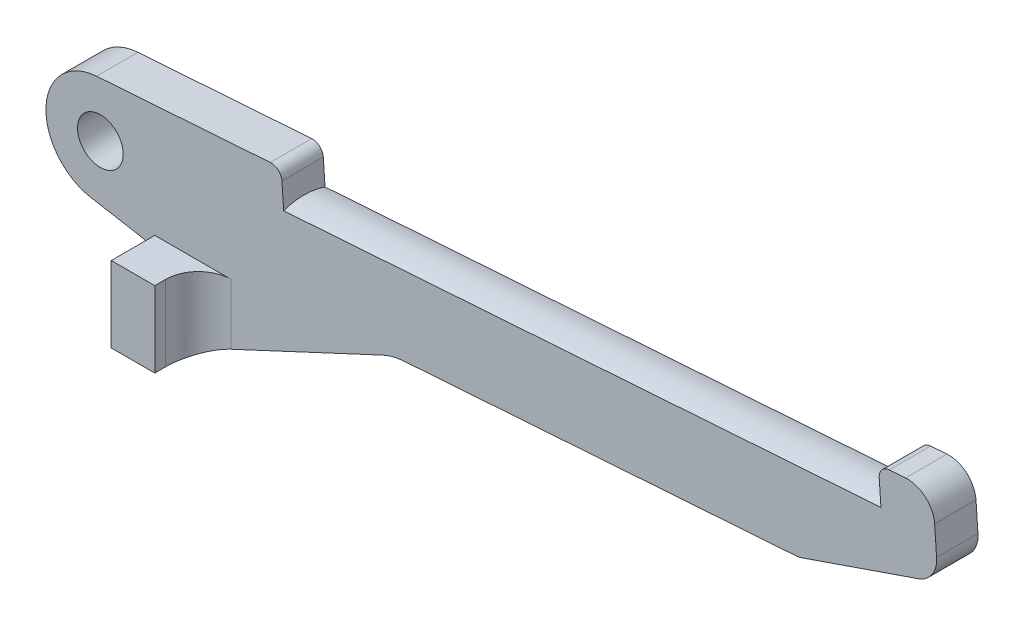
from build123d import *

# Parameters (mm, degrees)
SKETCH1_R           = 4.2
BOSS_EXTRUDE1_DEPTH = 7.6
SKETCH2_W           = 8
SKETCH2_H           = 13.917535926
BOSS_EXTRUDE2_DEPTH = 8
FILLET1_R           = 6
CUT_EXTRUDE2_DEPTH  = 110
FILLET2_R           = 2


with BuildPart() as part:
    # Sketch1 → Boss-Extrude1 (new body)
    with BuildSketch(Plane.XY):
        with BuildLine():
            Line((-1.736481777, -9.84807753), (7.520944533, -11.48041156))
            ThreePointArc((7.520944533, -11.48041156), (9.298133329, -12.50647199), (10, -14.434834819))
            Line((10, -14.434834819), (10, -23.917535926))
            Line((10, -23.917535926), (18, -23.917535926))
            Line((18, -23.917535926), (52.016628597, -8.055321506))
            ThreePointArc((52.016628597, -8.055321506), (53.739011174, -7.436922973), (55.545246477, -7.142758874))
            Line((55.545246477, -7.142758874), (127.674807922, -2.098968595))
            ThreePointArc((127.674807922, -2.098968595), (128.322865225, -2.010771867), (128.953866326, -1.838741222))
            Line((128.953866326, -1.838741222), (150.276280032, 5.503154599))
            ThreePointArc((150.276280032, 5.503154599), (152.81786837, 7.47106255), (153.636259511, 10.579529846))
            Line((153.636259511, 10.579529846), (153.276081371, 15.730317208))
            ThreePointArc((153.276081371, 15.730317208), (151.568556265, 19.15508274), (147.939478751, 20.36935509))
            Line((147.939478751, 20.36935509), (142.9516585, 20.020572722))
            Line((142.9516585, 20.020572722), (143.370197342, 14.03518842))
            Line((143.370197342, 14.03518842), (33.638151814, 6.361976308))
            Line((33.638151814, 6.361976308), (33.219612971, 12.34736061))
            Line((33.219612971, 12.34736061), (-0.697564737, 9.975640503))
            ThreePointArc((-0.697564737, 9.975640503), (-9.986295348, 0.523359562), (-1.736481777, -9.84807753))
        make_face()
        Circle(SKETCH1_R, mode=Mode.SUBTRACT)
    extrude(amount=BOSS_EXTRUDE1_DEPTH)

    # Sketch2 → Boss-Extrude2 (add)
    with BuildSketch(Plane.XY.offset(7.6)):
        with Locations((14, -16.958767963)):
            Rectangle(SKETCH2_W, SKETCH2_H)
    extrude(amount=BOSS_EXTRUDE2_DEPTH)

    # Fillet1
    fillet1_edges = [part.edges().sort_by_distance(p)[0] for p in [
        (18, -16.958767963, 7.6),
    ]]
    fillet(fillet1_edges, radius=FILLET1_R)

    # Sketch6 → Cut-Extrude2 (cut)
    with BuildSketch(Plane(origin=(22.512095066, 165.472000606, 0), x_dir=(0, 0, -1), z_dir=(-0.99756405, -0.069756474, 0))):
        with BuildLine():
            Line((-7.6, 160.116112141), (-7.6, 153.498554761))
            Line((-7.6, 153.498554761), (0, 153.498554761))
            Line((0, 153.498554761), (0, 160.116112141))
            ThreePointArc((0, 160.116112141), (-3.8, 159.498554761), (-7.6, 160.116112141))
        make_face()
    extrude(amount=-CUT_EXTRUDE2_DEPTH, mode=Mode.SUBTRACT)

    # Fillet2
    fillet2_edges = [part.edges().sort_by_distance(p)[0] for p in [
        (33.219612971, 12.34736061, 3.8),
        (142.9516585, 20.020572722, 3.8),
    ]]
    fillet(fillet2_edges, radius=FILLET2_R)


solid = part.part
